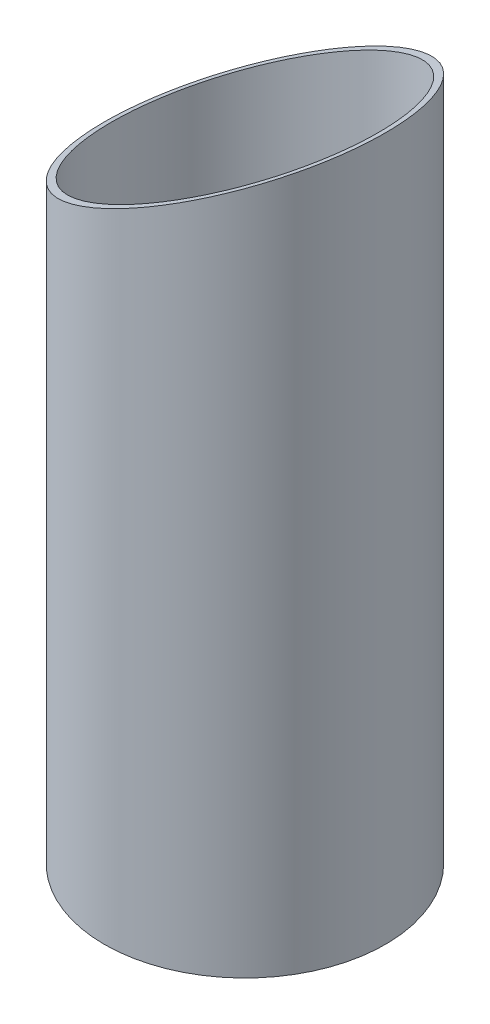
from build123d import *

# Parameters (mm, degrees)
ESQUISSE1_R                  = 40
ESQUISSE1_R_2                = 38
BOSS_EXTRU_1_DEPTH           = 300
ENL_V_MAT_EXTRU_1_DEPTH      = 50
ENL_V_MAT_EXTRU_1_DEPTH_BACK = 50


with BuildPart() as part:
    # Esquisse1 → Boss.-Extru.1 (new body)
    with BuildSketch(Plane(origin=(0, 0, 0), x_dir=(1, 0, 0), z_dir=(0, 1, 0))):
        with Locations(Location((0, 0, 0), (0, 0, 270))):  # turned: the seam where the file's is
            Circle(ESQUISSE1_R)
        with Locations(Location((0, 0, 0), (0, 0, 270))):  # turned: the seam where the file's is
            Circle(ESQUISSE1_R_2, mode=Mode.SUBTRACT)
    extrude(amount=BOSS_EXTRU_1_DEPTH)

    # Esquisse2 → Enl_v. mat.-Extru.1 (cut, two sides)
    with BuildSketch(Plane.XY) as enl_v_mat_extru_1_sk:
        Polygon((52.964597289, 206.045491001), (52.964597289, 318.753762587), (-71.343843605, 318.753762587), (-71.343843605, 148.079513039), align=None)
    extrude(amount=ENL_V_MAT_EXTRU_1_DEPTH, mode=Mode.SUBTRACT)
    extrude(enl_v_mat_extru_1_sk.sketch, amount=-ENL_V_MAT_EXTRU_1_DEPTH_BACK, mode=Mode.SUBTRACT)


solid = part.part
